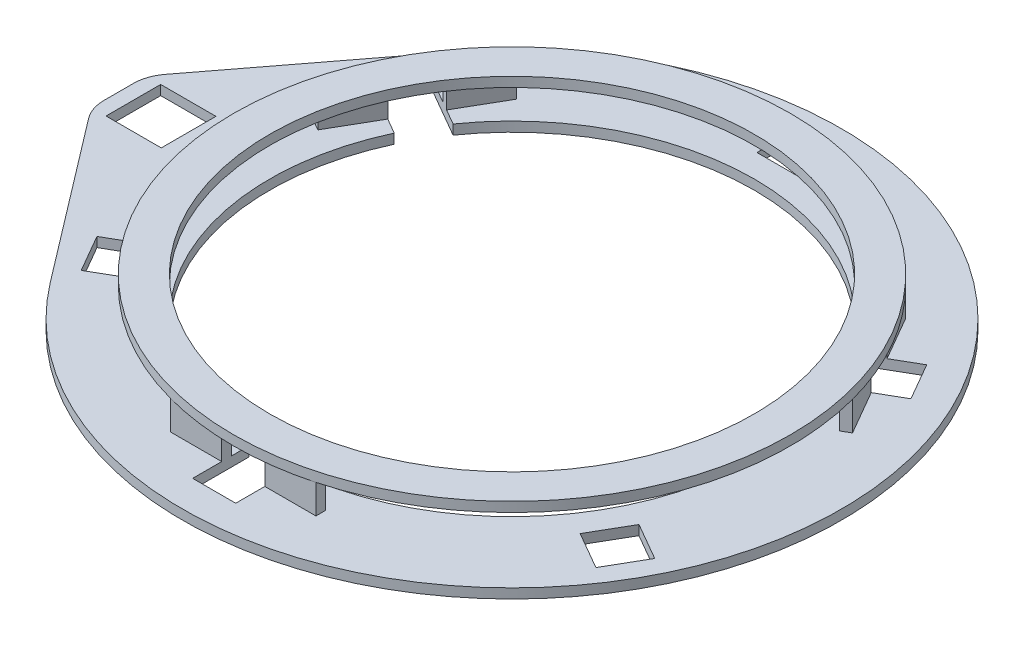
from build123d import *

# Parameters (mm, degrees)
SKETCH1_R           = 340
SKETCH1_R_2         = 250
SKETCH1_W           = 44.45
SKETCH1_H           = 44.45
BOSS_EXTRUDE1_DEPTH = 10
BOSS_EXTRUDE2_DEPTH = 40
SKETCH3_W           = 44.45
SKETCH3_H           = 44.45
CUT_EXTRUDE1_DEPTH  = 30
CIRPATTERN1_COUNT   = 3
BOSS_EXTRUDE3_START = -10
SKETCH4_R           = 287.263450512
SKETCH4_R_2         = 250
BOSS_EXTRUDE3_DEPTH = 10
BOSS_EXTRUDE4_DEPTH = 10
SKETCH6_W           = 57
SKETCH6_H           = 56.4
CUT_EXTRUDE2_DEPTH  = 10


with BuildPart() as part:
    # Sketch1 → Boss-Extrude1 (new body)
    with BuildSketch(Plane(origin=(0, 0, 0), x_dir=(1, 0, 0), z_dir=(0, 1, 0))):
        Circle(SKETCH1_R)
        Circle(SKETCH1_R_2, mode=Mode.SUBTRACT)
        with Locations((0, 297.225)):
            Rectangle(SKETCH1_W, SKETCH1_H, mode=Mode.SUBTRACT)
        Polygon((287.764315239, -140.477585401), (249.269486041, -118.252585401), (227.044486041, -156.747414599), (265.539315239, -178.972414599), align=None, mode=Mode.SUBTRACT)
        Polygon((-265.539315239, -178.972414599), (-227.044486041, -156.747414599), (-249.269486041, -118.252585401), (-287.764315239, -140.477585401), align=None, mode=Mode.SUBTRACT)
    extrude(amount=BOSS_EXTRUDE1_DEPTH)

    # Sketch2 → Boss-Extrude2 (add)
    with BuildSketch(Plane(origin=(0, 10, 0), x_dir=(1, 0, 0), z_dir=(0, 1, 0))):
        Polygon((22.25, -267.3), (-22.25, -267.3), (-75, -267.3), (-75, -277.3), (-22.25, -277.3), (22.25, -277.3), (75, -277.3), (75, -267.3), align=None)
        Polygon((-229.023844469, 157.919065234), (-202.648844469, 203.601905284), (-193.988590432, 198.601905284), (-220.363590432, 152.919065234), (-242.613590432, 114.380934766), (-268.988590432, 68.698094716), (-277.648844469, 73.698094716), (-251.273844469, 119.380934766), align=None)
        Polygon((251.273844469, 119.380934766), (277.648844469, 73.698094716), (268.988590432, 68.698094716), (242.613590432, 114.380934766), (220.363590432, 152.919065234), (193.988590432, 198.601905284), (202.648844469, 203.601905284), (229.023844469, 157.919065234), align=None)
    extrude(amount=BOSS_EXTRUDE2_DEPTH)

    # Sketch3 → Cut-Extrude1 (cut, symmetric)
    with BuildSketch(Plane.XY.offset(277.3)):
        with Locations((0, 16.699086593)):
            Rectangle(SKETCH3_W, SKETCH3_H)
    cut_extrude1 = extrude(amount=CUT_EXTRUDE1_DEPTH, both=True, mode=Mode.SUBTRACT)

    # CirPattern1: Cut-Extrude1 ×3 about axis
    cirpattern1_axis = Axis((0, 52.77629567, 0), (0, -1, 0))
    for i in range(1, CIRPATTERN1_COUNT):
        add(cut_extrude1.rotate(cirpattern1_axis, i * 360 / CIRPATTERN1_COUNT), mode=Mode.SUBTRACT)

    # Sketch4 → Boss-Extrude3 (add)
    with BuildSketch(Plane(origin=(0, 50, 0), x_dir=(1, 0, 0), z_dir=(0, 1, 0)).offset(BOSS_EXTRUDE3_START)):
        Circle(SKETCH4_R)
        Circle(SKETCH4_R_2, mode=Mode.SUBTRACT)
    extrude(amount=BOSS_EXTRUDE3_DEPTH)

    # Sketch5 → Boss-Extrude4 (add)
    with BuildSketch(Plane(origin=(0, 0, 0), x_dir=(1, 0, 0), z_dir=(0, 1, 0))):
        with BuildLine():
            Line((-397.510704876, 39.376941903), (-270.390991444, 206.127901425))
            Line((-270.390991444, 206.127901425), (-330.879136225, 0))
            Line((-330.879136225, 0), (-270.390991444, -206.127901425))
            Line((-270.390991444, -206.127901425), (-397.510704876, -39.376941903))
            ThreePointArc((-397.510704876, -39.376941903), (-403.597415446, -27.924487201), (-405.7, -15.126600559))
            Line((-405.7, -15.126600559), (-405.7, 15.126600559))
            ThreePointArc((-405.7, 15.126600559), (-403.597415446, 27.924487201), (-397.510704876, 39.376941903))
        make_face()
        Polygon((-390.7, 0), (-390.7, 28.2), (-333.7, 28.2), (-333.7, -28.2), (-390.7, -28.2), align=None, mode=Mode.SUBTRACT)
    extrude(amount=BOSS_EXTRUDE4_DEPTH)

    # Sketch6 → Cut-Extrude2 (cut)
    with BuildSketch(Plane(origin=(0, 10, 0), x_dir=(-1, 0, 0), z_dir=(0, 1, 0))):
        with Locations((362.2, 0)):
            Rectangle(SKETCH6_W, SKETCH6_H)
    extrude(amount=-CUT_EXTRUDE2_DEPTH, mode=Mode.SUBTRACT)


solid = part.part
